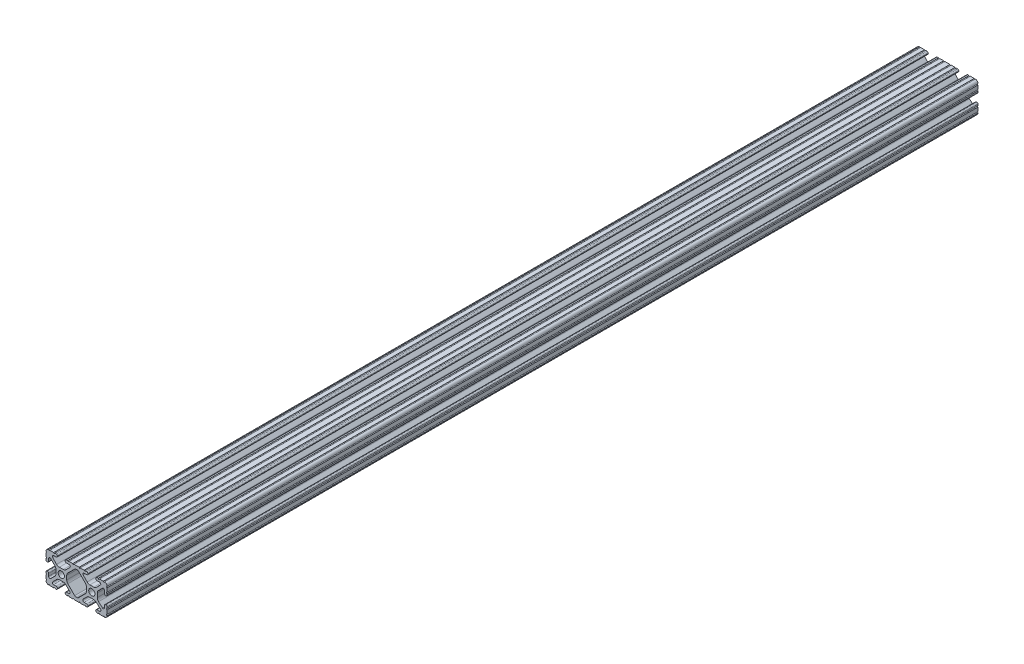
from build123d import *

# Parameters (mm, degrees)
SKETCH1_R           = 2.6035
BOSS_EXTRUDE1_DEPTH = 361.95


with BuildPart() as part:
    # Sketch1 → Boss-Extrude1 (new body, symmetric)
    with BuildSketch(Plane.XY):
        with BuildLine():
            Line((18.01710265, 12.7), (16.98745015, 12.7))
            ThreePointArc((16.98745015, 12.7), (16.245730386, 12.392769614), (15.9385, 11.65104985))
            Line((15.9385, 11.65104985), (15.9385, 11.53922))
            ThreePointArc((15.9385, 11.53922), (16.245750844, 10.797450844), (16.98752, 10.4902))
            Line((16.98752, 10.4902), (19.116384363, 10.4902))
            ThreePointArc((19.116384363, 10.4902), (20.052502933, 9.869096983), (19.844087081, 8.765172272))
            Line((19.844087081, 8.765172272), (16.618993479, 5.455112286))
            ThreePointArc((16.618993479, 5.455112286), (15.578994274, 4.745442459), (14.344932584, 4.4958))
            Line((14.344932584, 4.4958), (11.083317835, 4.4958))
            ThreePointArc((11.083317835, 4.4958), (9.854330953, 4.743306833), (8.816955189, 5.447238587))
            Line((8.816955189, 5.447238587), (5.564154119, 8.762652677))
            ThreePointArc((5.564154119, 8.762652677), (5.352591412, 9.867473037), (6.289393385, 10.4902))
            Line((6.289393385, 10.4902), (8.41248, 10.4902))
            ThreePointArc((8.41248, 10.4902), (9.154249156, 10.797450844), (9.4615, 11.53922))
            Line((9.4615, 11.53922), (9.4615, 11.65104985))
            ThreePointArc((9.4615, 11.65104985), (9.154269614, 12.392769614), (8.41254985, 12.7))
            Line((8.41254985, 12.7), (7.38288465, 12.7))
            ThreePointArc((7.38288465, 12.7), (6.87488465, 12.192), (6.36688465, 12.7))
            Line((6.36688465, 12.7), (3.14958095, 12.7))
            ThreePointArc((3.14958095, 12.7), (2.64158095, 12.192), (2.13358095, 12.7))
            Line((2.13358095, 12.7), (-2.13358095, 12.7))
            ThreePointArc((-2.13358095, 12.7), (-2.64158095, 12.192), (-3.14958095, 12.7))
            Line((-3.14958095, 12.7), (-6.36689735, 12.7))
            ThreePointArc((-6.36689735, 12.7), (-6.87489735, 12.192), (-7.38289735, 12.7))
            Line((-7.38289735, 12.7), (-8.41254985, 12.7))
            ThreePointArc((-8.41254985, 12.7), (-9.154269614, 12.392769614), (-9.4615, 11.65104985))
            Line((-9.4615, 11.65104985), (-9.4615, 11.53922))
            ThreePointArc((-9.4615, 11.53922), (-9.154249156, 10.797450844), (-8.41248, 10.4902))
            Line((-8.41248, 10.4902), (-6.283641037, 10.4902))
            ThreePointArc((-6.283641037, 10.4902), (-5.297291557, 9.829633109), (-5.532576693, 8.666071843))
            Line((-5.532576693, 8.666071843), (-8.809985098, 5.416263103))
            ThreePointArc((-8.809985098, 5.416263103), (-9.836720513, 4.734920264), (-11.045536121, 4.4958))
            Line((-11.045536121, 4.4958), (-14.354463879, 4.4958))
            ThreePointArc((-14.354463879, 4.4958), (-15.563279487, 4.734920264), (-16.590014902, 5.416263103))
            Line((-16.590014902, 5.416263103), (-19.867423307, 8.666071843))
            ThreePointArc((-19.867423307, 8.666071843), (-20.102708443, 9.829633109), (-19.116358963, 10.4902))
            Line((-19.116358963, 10.4902), (-16.98752, 10.4902))
            ThreePointArc((-16.98752, 10.4902), (-16.245750844, 10.797450844), (-15.9385, 11.53922))
            Line((-15.9385, 11.53922), (-15.9385, 11.65104985))
            ThreePointArc((-15.9385, 11.65104985), (-16.245730386, 12.392769614), (-16.98745015, 12.7))
            Line((-16.98745015, 12.7), (-18.01711535, 12.7))
            ThreePointArc((-18.01711535, 12.7), (-18.52511535, 12.192), (-19.03311535, 12.7))
            Line((-19.03311535, 12.7), (-22.2504, 12.7))
            ThreePointArc((-22.2504, 12.7), (-22.758323491, 12.192000006), (-23.266399977, 12.699846982))
            ThreePointArc((-23.266399977, 12.699846982), (-24.782522516, 12.082522516), (-25.399846982, 10.566399977))
            ThreePointArc((-25.399846982, 10.566399977), (-24.892000006, 10.058323491), (-25.4, 9.5504))
            Line((-25.4, 9.5504), (-25.4, 6.3330836))
            ThreePointArc((-25.4, 6.3330836), (-24.892, 5.8250836), (-25.4, 5.3170836))
            Line((-25.4, 5.3170836), (-25.4, 4.237520184))
            ThreePointArc((-25.4, 4.237520184), (-25.107393763, 3.531106237), (-24.400979816, 3.2385))
            Line((-24.400979816, 3.2385), (-24.23922, 3.2385))
            ThreePointArc((-24.23922, 3.2385), (-23.497450844, 3.545750844), (-23.1902, 4.28752))
            Line((-23.1902, 4.28752), (-23.1902, 6.334741132))
            ThreePointArc((-23.1902, 6.334741132), (-22.556026952, 7.286023527), (-21.434002553, 7.066535717))
            Line((-21.434002553, 7.066535717), (-18.147950853, 3.808156468))
            ThreePointArc((-18.147950853, 3.808156468), (-17.452759693, 2.774838327), (-17.208501877, 1.553619571))
            Line((-17.208501877, 1.553619571), (-17.208501877, -1.695179196))
            ThreePointArc((-17.208501877, -1.695179196), (-17.450738657, -2.911536421), (-18.140486065, -3.942289578))
            Line((-18.140486065, -3.942289578), (-21.431579576, -7.227386226))
            ThreePointArc((-21.431579576, -7.227386226), (-22.55444896, -7.449940594), (-23.1902, -6.498002195))
            Line((-23.1902, -6.498002195), (-23.1902, -4.28752))
            ThreePointArc((-23.1902, -4.28752), (-23.497450844, -3.545750844), (-24.23922, -3.2385))
            Line((-24.23922, -3.2385), (-24.35098, -3.2385))
            ThreePointArc((-24.35098, -3.2385), (-25.092749156, -3.545750844), (-25.4, -4.28752))
            Line((-25.4, -4.28752), (-25.4, -5.3171344))
            ThreePointArc((-25.4, -5.3171344), (-24.892, -5.8251344), (-25.4, -6.3331344))
            Line((-25.4, -6.3331344), (-25.4, -9.5504))
            ThreePointArc((-25.4, -9.5504), (-24.892000006, -10.058323491), (-25.399846982, -10.566399977))
            ThreePointArc((-25.399846982, -10.566399977), (-24.782522516, -12.082522516), (-23.266399977, -12.699846982))
            ThreePointArc((-23.266399977, -12.699846982), (-22.758323491, -12.192000006), (-22.2504, -12.7))
            Line((-22.2504, -12.7), (-19.03308995, -12.7))
            ThreePointArc((-19.03308995, -12.7), (-18.52508995, -12.192), (-18.01708995, -12.7))
            Line((-18.01708995, -12.7), (-16.9874692, -12.7))
            ThreePointArc((-16.9874692, -12.7), (-16.245700044, -12.392749156), (-15.9384492, -11.65098))
            Line((-15.9384492, -11.65098), (-15.9384492, -11.53922))
            ThreePointArc((-15.9384492, -11.53922), (-16.245700044, -10.797450844), (-16.9874692, -10.4902))
            Line((-16.9874692, -10.4902), (-19.116358963, -10.4902))
            ThreePointArc((-19.116358963, -10.4902), (-20.055197748, -9.862578342), (-19.834124023, -8.755124678))
            Line((-19.834124023, -8.755124678), (-16.49660751, -5.423689618))
            ThreePointArc((-16.49660751, -5.423689618), (-15.467274017, -4.736928798), (-14.253591699, -4.4958))
            Line((-14.253591699, -4.4958), (-11.146408301, -4.4958))
            ThreePointArc((-11.146408301, -4.4958), (-9.932725983, -4.736928798), (-8.90339249, -5.423689618))
            Line((-8.90339249, -5.423689618), (-5.565875977, -8.755124678))
            ThreePointArc((-5.565875977, -8.755124678), (-5.344802252, -9.862578342), (-6.283641037, -10.4902))
            Line((-6.283641037, -10.4902), (-8.4125308, -10.4902))
            ThreePointArc((-8.4125308, -10.4902), (-9.154299956, -10.797450844), (-9.4615508, -11.53922))
            Line((-9.4615508, -11.53922), (-9.4615508, -11.65098))
            ThreePointArc((-9.4615508, -11.65098), (-9.154299956, -12.392749156), (-8.4125308, -12.7))
            Line((-8.4125308, -12.7), (-7.38287195, -12.7))
            ThreePointArc((-7.38287195, -12.7), (-6.87487195, -12.192), (-6.36687195, -12.7))
            Line((-6.36687195, -12.7), (-3.14960635, -12.7))
            ThreePointArc((-3.14960635, -12.7), (-2.64160635, -12.192), (-2.13360635, -12.7))
            Line((-2.13360635, -12.7), (2.13360635, -12.7))
            ThreePointArc((2.13360635, -12.7), (2.64159365, -12.1920127), (3.14958095, -12.7))
            Line((3.14958095, -12.7), (6.36691005, -12.7))
            ThreePointArc((6.36691005, -12.7), (6.87491005, -12.192), (7.38291005, -12.7))
            Line((7.38291005, -12.7), (8.4125308, -12.7))
            ThreePointArc((8.4125308, -12.7), (9.154299956, -12.392749156), (9.4615508, -11.65098))
            Line((9.4615508, -11.65098), (9.4615508, -11.53922))
            ThreePointArc((9.4615508, -11.53922), (9.154299956, -10.797450844), (8.4125308, -10.4902))
            Line((8.4125308, -10.4902), (6.289393385, -10.4902))
            ThreePointArc((6.289393385, -10.4902), (5.231590322, -9.783049717), (5.480677245, -8.535265862))
            Line((5.480677245, -8.535265862), (8.597933595, -5.423689618))
            ThreePointArc((8.597933595, -5.423689618), (9.627267088, -4.736928798), (10.840949406, -4.4958))
            Line((10.840949406, -4.4958), (14.102564155, -4.4958))
            ThreePointArc((14.102564155, -4.4958), (15.215927525, -4.697410182), (16.187895372, -5.276636531))
            Line((16.187895372, -5.276636531), (19.868247549, -8.482246082))
            ThreePointArc((19.868247549, -8.482246082), (20.188435806, -9.746879864), (19.116384363, -10.4902))
            Line((19.116384363, -10.4902), (16.9874692, -10.4902))
            ThreePointArc((16.9874692, -10.4902), (16.245700044, -10.797450844), (15.9384492, -11.53922))
            Line((15.9384492, -11.53922), (15.9384492, -11.65098))
            ThreePointArc((15.9384492, -11.65098), (16.245700044, -12.392749156), (16.9874692, -12.7))
            Line((16.9874692, -12.7), (18.01710265, -12.7))
            ThreePointArc((18.01710265, -12.7), (18.52510265, -12.192), (19.03310265, -12.7))
            Line((19.03310265, -12.7), (22.2504, -12.7))
            ThreePointArc((22.2504, -12.7), (22.758323491, -12.192000006), (23.266399977, -12.699846982))
            ThreePointArc((23.266399977, -12.699846982), (24.782522516, -12.082522516), (25.399846982, -10.566399977))
            ThreePointArc((25.399846982, -10.566399977), (24.892000006, -10.058323492), (25.4, -9.550400001))
            Line((25.4, -9.550400001), (25.4, -6.333083592))
            ThreePointArc((25.4, -6.333083592), (24.892000001, -5.825083593), (25.4, -5.317083593))
            Line((25.4, -5.317083593), (25.4, -4.237520184))
            ThreePointArc((25.4, -4.237520184), (25.107393763, -3.531106237), (24.400979816, -3.2385))
            Line((24.400979816, -3.2385), (24.189220184, -3.2385))
            ThreePointArc((24.189220184, -3.2385), (23.482806237, -3.531106237), (23.1902, -4.237520184))
            Line((23.1902, -4.237520184), (23.1902, -6.155876159))
            ThreePointArc((23.1902, -6.155876159), (22.62232736, -7.038258539), (21.583974541, -6.886926384))
            Line((21.583974541, -6.886926384), (18.29817066, -4.024970844))
            ThreePointArc((18.29817066, -4.024970844), (17.493730985, -2.946044689), (17.208501877, -1.630807374))
            Line((17.208501877, -1.630807374), (17.208501877, 1.630807374))
            ThreePointArc((17.208501877, 1.630807374), (17.442348332, 2.82673414), (18.109440981, 3.846495088))
            Line((18.109440981, 3.846495088), (21.526346532, 7.353420386))
            ThreePointArc((21.526346532, 7.353420386), (22.585896263, 7.574939077), (23.1902, 6.676867167))
            Line((23.1902, 6.676867167), (23.1902, 4.237520184))
            ThreePointArc((23.1902, 4.237520184), (23.482806237, 3.531106237), (24.189220184, 3.2385))
            Line((24.189220184, 3.2385), (24.400979816, 3.2385))
            ThreePointArc((24.400979816, 3.2385), (25.107393763, 3.531106237), (25.4, 4.237520184))
            Line((25.4, 4.237520184), (25.4, 5.3170836))
            ThreePointArc((25.4, 5.3170836), (24.891949193, 5.825134407), (25.4, 6.333185215))
            Line((25.4, 6.333185215), (25.4, 9.550400015))
            ThreePointArc((25.4, 9.550400015), (24.892000013, 10.058323498), (25.399846982, 10.566399977))
            ThreePointArc((25.399846982, 10.566399977), (24.782522516, 12.082522516), (23.266399977, 12.699846982))
            ThreePointArc((23.266399977, 12.699846982), (22.758323491, 12.192000006), (22.2504, 12.7))
            Line((22.2504, 12.7), (19.03310265, 12.7))
            ThreePointArc((19.03310265, 12.7), (18.52510265, 12.192), (18.01710265, 12.7))
        make_face()
        with Locations((-12.7, 0)):
            Circle(SKETCH1_R, mode=Mode.SUBTRACT)
        with Locations((12.7, 0)):
            Circle(SKETCH1_R, mode=Mode.SUBTRACT)
        with BuildLine():
            Line((-7.259513935, -3.869413038), (-1.545748891, -9.572766749))
            ThreePointArc((-1.545748891, -9.572766749), (-1.035199478, -9.913400116), (-0.433213048, -10.033))
            Line((-0.433213048, -10.033), (0.433213048, -10.033))
            ThreePointArc((0.433213048, -10.033), (1.035199478, -9.913400116), (1.545748891, -9.572766749))
            Line((1.545748891, -9.572766749), (7.259513935, -3.869413038))
            ThreePointArc((7.259513935, -3.869413038), (7.949261343, -2.838659881), (8.191498123, -1.622302656))
            Line((8.191498123, -1.622302656), (8.191498123, 1.622302656))
            ThreePointArc((8.191498123, 1.622302656), (7.955573352, 2.823327967), (7.282860769, 3.845864069))
            Line((7.282860769, 3.845864069), (1.675572808, 9.561086461))
            ThreePointArc((1.675572808, 9.561086461), (1.161034429, 9.910236611), (0.551456936, 10.033))
            Line((0.551456936, 10.033), (-0.395199982, 10.033))
            ThreePointArc((-0.395199982, 10.033), (-0.994772524, 9.914396349), (-1.50403329, 9.576450301))
            Line((-1.50403329, 9.576450301), (-7.252049147, 3.876839553))
            ThreePointArc((-7.252049147, 3.876839553), (-7.947240307, 2.843521412), (-8.191498123, 1.622302656))
            Line((-8.191498123, 1.622302656), (-8.191498123, -1.622302656))
            ThreePointArc((-8.191498123, -1.622302656), (-7.949261343, -2.838659881), (-7.259513935, -3.869413038))
        make_face(mode=Mode.SUBTRACT)
    extrude(amount=BOSS_EXTRUDE1_DEPTH, both=True)


solid = part.part
